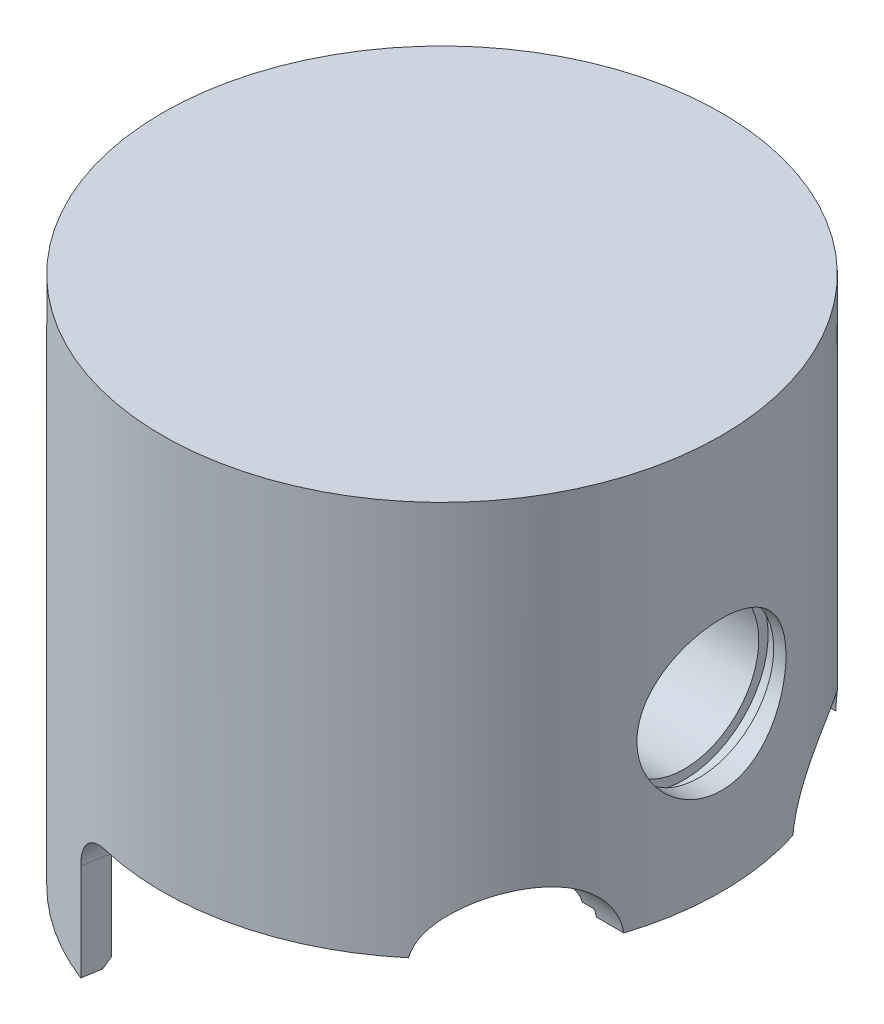
from build123d import *

# Parameters (mm, degrees)
CUT_EXTRUDE1_DEPTH      = 3.6
FILLET1_R               = 1
CUT_EXTRUDE2_DEPTH      = 10.1
CUT_EXTRUDE3_DEPTH      = 8.5000001
CUT_EXTRUDE4_REACH      = 12
CUT_EXTRUDE4_END_RADIUS = 2
SKETCH6_R               = 0.5
CHAMFER1_SIZE           = 0.2


with BuildPart() as part:
    # Sketch1 → Revolve1 (revolve)
    with BuildSketch(Plane.XY, mode=Mode.PRIVATE) as revolve1_sk:
        with BuildLine():
            Line((0, 0), (7.5, 0))
            Line((7.5, 0), (7.5, -14.2))
            Line((7.5, -14.2), (7, -14.2))
            Line((7, -14.2), (6.8, -14))
            Line((6.8, -14), (6.8, -10.4))
            Line((6.8, -10.4), (6.5, -10.4))
            Line((6.5, -10.4), (6.5, -10.3))
            ThreePointArc((6.5, -10.3), (6.412132034, -10.087867966), (6.2, -10))
            Line((6.2, -10), (0, -10))
            Line((0, -10), (0, 0))
        make_face()
    revolve(revolve1_sk.sketch.rotate(Axis((0, -10, 0), (0, -1, 0)), 180), axis=Axis((0, -10, 0), (0, -1, 0)))  # turned: the seam where the file's is

    # Sketch2 → Cut-Revolve1 (revolve, cut)
    with BuildSketch(Plane.XY, mode=Mode.PRIVATE) as cut_revolve1_sk:
        Polygon((-6.5, -4.25), (6.5, -4.25), (6.5, -4), (6.9, -4), (6.9, -4.25), (7.5, -4.25), (7.5, -6.25), (-7.5, -6.25), (-7.5, -4.25), (-6.9, -4.25), (-6.9, -4), (-6.5, -4), align=None)
    revolve(cut_revolve1_sk.sketch.rotate(Axis((7.5, -6.25, 0), (1, 0, 0)), 90), axis=Axis((7.5, -6.25, 0), (1, 0, 0)), mode=Mode.SUBTRACT)  # turned: the seam where the file's is

    # Sketch3 → Cut-Extrude1 (cut)
    with BuildSketch(Plane.XZ.offset(14.2)):
        with BuildLine():
            Line((-2.574381753, 6.293850856), (-2.692582404, 7))
            ThreePointArc((-2.692582404, 7), (7.5, 0), (-2.692582404, -7))
            Line((-2.692582404, -7), (-2.574381753, -6.293850856))
            ThreePointArc((-2.574381753, -6.293850856), (6.8, 0), (-2.574381753, 6.293850856))
        make_face()
    extrude(amount=-CUT_EXTRUDE1_DEPTH, mode=Mode.SUBTRACT)

    # Fillet1
    fillet1_edges = [part.edges().sort_by_distance(p)[0] for p in [
        (-2.633482078, -10.6, -6.646925428),
        (-2.633482078, -10.6, 6.646925428),
    ]]
    fillet(fillet1_edges, radius=FILLET1_R)

    # Sketch4 → Cut-Extrude2 (cut)
    with BuildSketch(Plane.XZ.offset(10.6)):
        with BuildLine():
            Line((3, -2.5), (3, 2.5))
            ThreePointArc((3, 2.5), (4.423024947, 3.525658351), (3.9, 5.2))
            ThreePointArc((3.9, 5.2), (0, 6.5), (-3.9, 5.2))
            ThreePointArc((-3.9, 5.2), (-4.423024947, 3.525658351), (-3, 2.5))
            Line((-3, 2.5), (-3, -2.5))
            ThreePointArc((-3, -2.5), (-4.423024947, -3.525658351), (-3.9, -5.2))
            ThreePointArc((-3.9, -5.2), (0, -6.5), (3.9, -5.2))
            ThreePointArc((3.9, -5.2), (4.423024947, -3.525658351), (3, -2.5))
        make_face()
    extrude(amount=-CUT_EXTRUDE2_DEPTH, mode=Mode.SUBTRACT)

    # Sketch5 → Cut-Extrude3 (cut, through all)
    with BuildSketch(Plane(origin=(0, 0, 0), x_dir=(0, 0, -1), z_dir=(1, 0, 0))):
        with BuildLine():
            Line((-2.267949192, -10.6), (2.267949192, -10.6))
            ThreePointArc((2.267949192, -10.6), (5.322875656, -9.704356076), (4, -12.6))
            Line((4, -12.6), (-4, -12.6))
            ThreePointArc((-4, -12.6), (-5.322875656, -9.704356076), (-2.267949192, -10.6))
        make_face()
    extrude(amount=CUT_EXTRUDE3_DEPTH, mode=Mode.SUBTRACT)

    # Cut-Extrude4: up to this cylinder (the profile starts outside it)
    cut_extrude4_end = Plane(origin=(0, -6.25, 0), z_dir=(-1, 0, 0)) * Cylinder(CUT_EXTRUDE4_END_RADIUS, 38, mode=Mode.PRIVATE)
    # Sketch6 → Cut-Extrude4 (cut, up to the surface)
    with BuildSketch(Plane.XZ.offset(10), mode=Mode.PRIVATE) as cut_extrude4_sk1:
        with Locations((-4.5, 0)):
            Circle(SKETCH6_R)
    cut_extrude4_tool1 = extrude(cut_extrude4_sk1.sketch, amount=-CUT_EXTRUDE4_REACH, mode=Mode.PRIVATE) - cut_extrude4_end
    add(cut_extrude4_tool1.solids().sort_by_distance((-4.5, -10, 0))[0], mode=Mode.SUBTRACT)
    # Sketch6 → Cut-Extrude4 (cut, up to the surface)
    with BuildSketch(Plane.XZ.offset(10), mode=Mode.PRIVATE) as cut_extrude4_sk2:
        with Locations((4.5, 0)):
            Circle(SKETCH6_R)
    cut_extrude4_tool2 = extrude(cut_extrude4_sk2.sketch, amount=-CUT_EXTRUDE4_REACH, mode=Mode.PRIVATE) - cut_extrude4_end
    add(cut_extrude4_tool2.solids().sort_by_distance((4.5, -10, 0))[0], mode=Mode.SUBTRACT)

    # Chamfer1
    chamfer1_edges = [part.edges().sort_by_distance(p)[0] for p in [
        (-5, -10, 0),
        (4, -10, 0),
    ]]
    chamfer(chamfer1_edges, length=CHAMFER1_SIZE)


solid = part.part
